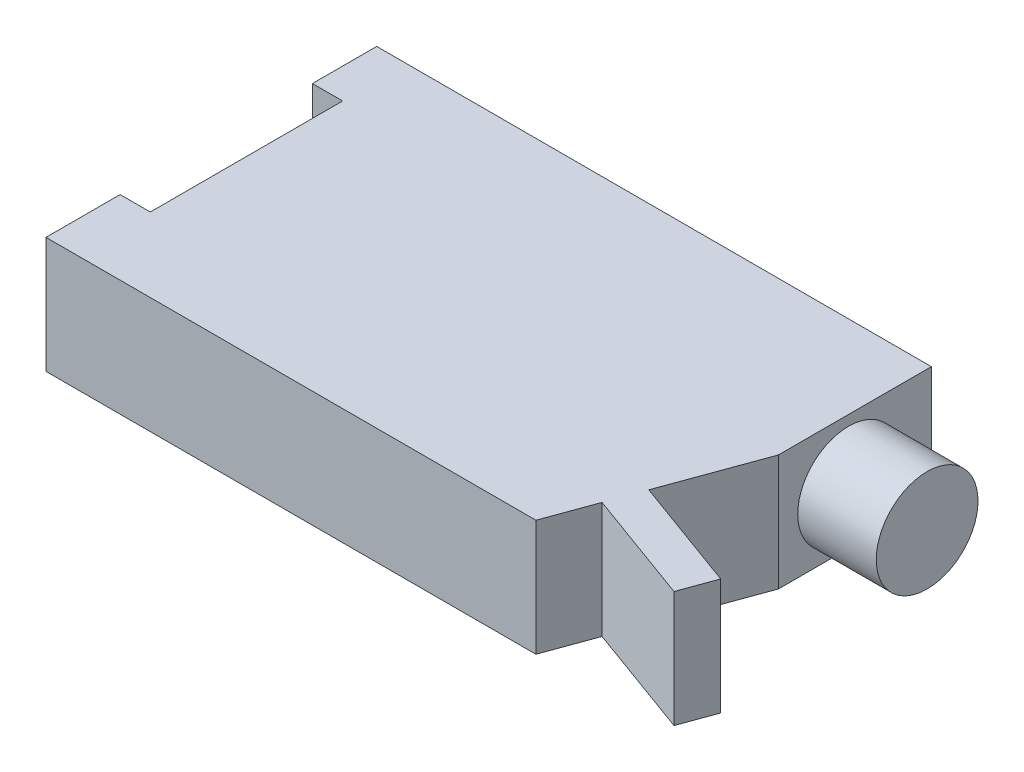
from build123d import *

# Parameters (mm, degrees)
BOSS_EXTRUDE1_DEPTH = 20
SKETCH2_R           = 8.762238692
BOSS_EXTRUDE2_DEPTH = 13.528179
SKETCH3_W           = 5.200821941
SKETCH3_H           = 33.128455843
CUT_EXTRUDE1_DEPTH  = 69.647143148


with BuildPart() as part:
    # Sketch1 → Boss-Extrude1 (new body)
    with BuildSketch(Plane(origin=(0, 0, 0), x_dir=(1, 0, 0), z_dir=(0, 1, 0))):
        Polygon((37.062970991, 27.075407166), (37.062970991, 0.732918261), (31.104831338, -15.636935896), (50.591147993, -22.729375134), (48.442612656, -28.632427455), (28.956296002, -21.539988217), (25.917709331, -29.888436482), (-58.473170148, -29.888436482), (-58.473170148, 27.075407166), align=None)
    extrude(amount=BOSS_EXTRUDE1_DEPTH)

    # Sketch2 → Boss-Extrude2 (add)
    with BuildSketch(Plane(origin=(37.062970991, 0, 0), x_dir=(0, 0, -1), z_dir=(1, 0, 0))):
        with Locations(Location((12.821734178, 9.480390425, 0), (0, 0, 180))):
            Circle(SKETCH2_R)
    extrude(amount=BOSS_EXTRUDE2_DEPTH)

    # Sketch3 → Cut-Extrude1 (cut, through all)
    with BuildSketch(Plane(origin=(0, 20, 0), x_dir=(1, 0, 0), z_dir=(0, 1, 0))):
        with Locations((-55.872759178, -0.563117172)):
            Rectangle(SKETCH3_W, SKETCH3_H)
    extrude(amount=-CUT_EXTRUDE1_DEPTH, mode=Mode.SUBTRACT)


solid = part.part
